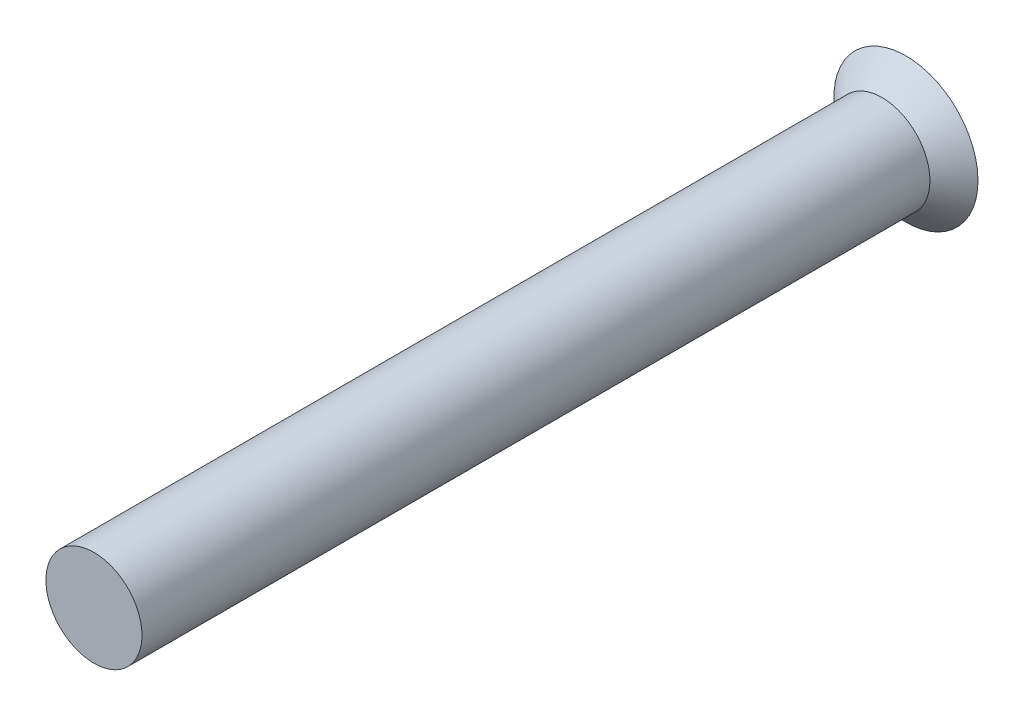
from build123d import *

# Parameters (mm, degrees)
SKETCH1_R           = 0.5
BOSS_EXTRUDE1_DEPTH = 4.1
CUT_EXTRUDE1_DEPTH  = 0.1


with BuildPart() as part:
    # Sketch1 → Boss-Extrude1 (new body, symmetric)
    with BuildSketch(Plane.XY):
        Circle(SKETCH1_R)
    extrude(amount=BOSS_EXTRUDE1_DEPTH, both=True)

    # Sketch2 → Revolve1 (revolve)
    with BuildSketch(Plane(origin=(0, 0, 0), x_dir=(0, 0, -1), z_dir=(1, 0, 0))):
        Polygon((4.35, 0.75), (4.35, 0), (4.1, 0), (4.1, 0.5), align=None)
    revolve(axis=Axis((0, 0, 2.0805), (0, 0, -1)))

    # Sketch3 → Cut-Extrude1 (cut)
    with BuildSketch(Plane(origin=(0, 0, -4.35), x_dir=(-1, 0, 0), z_dir=(0, 0, -1))):
        Polygon((0.1, 0.6), (-0.1, 0.6), (-0.1, 0.1), (-0.6, 0.1), (-0.6, -0.1), (-0.105645494, -0.1), (-0.105645494, -0.6), (0.105645494, -0.6), (0.105645494, -0.1), (0.6, -0.1), (0.6, 0.1), (0.1, 0.1), align=None)
    extrude(amount=-CUT_EXTRUDE1_DEPTH, mode=Mode.SUBTRACT)


solid = part.part
